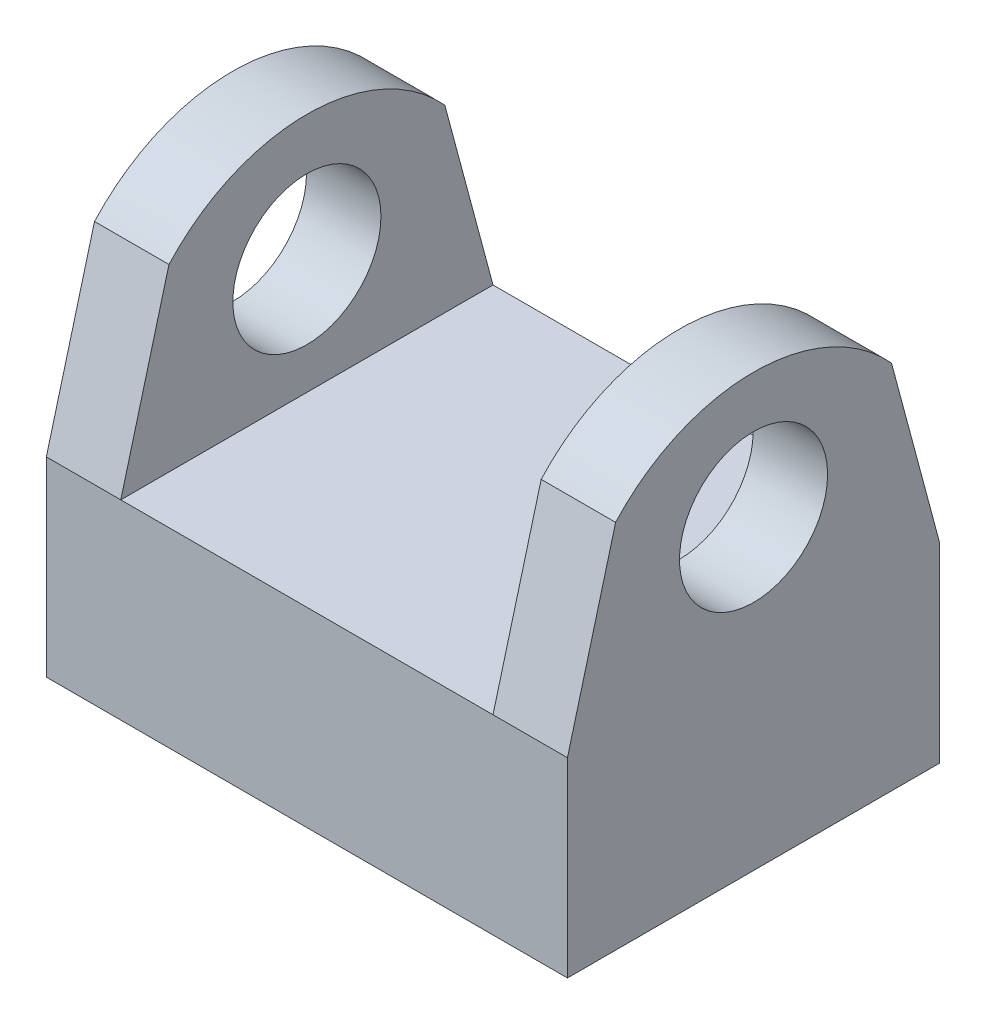
from build123d import *

# Parameters (mm, degrees)
SKETCH1_W           = 35.56
SKETCH1_H           = 25.4
BOSS_EXTRUDE1_DEPTH = 13.0175
BOSS_EXTRUDE2_DEPTH = 5.08
SKETCH3_R           = 5.053169443
CUT_EXTRUDE1_DEPTH  = 36.56


with BuildPart() as part:
    # Sketch1 → Boss-Extrude1 (new body)
    with BuildSketch(Plane(origin=(0, 0, 0), x_dir=(1, 0, 0), z_dir=(0, 1, 0))):
        Rectangle(SKETCH1_W, SKETCH1_H)
    extrude(amount=BOSS_EXTRUDE1_DEPTH)

    # Sketch2 → Boss-Extrude2 (add)
    with BuildSketch(Plane(origin=(17.78, 0, 0), x_dir=(0, 0, -1), z_dir=(1, 0, 0))):
        with BuildLine():
            Line((-12.7, 13.0175), (-9.412998127, 25.284757994))
            ThreePointArc((-9.412998127, 25.284757994), (0, 29.45408338), (9.412998127, 25.284757994))
            Line((9.412998127, 25.284757994), (12.7, 13.0175))
            Line((12.7, 13.0175), (-12.7, 13.0175))
        make_face()
    boss_extrude2 = extrude(amount=-BOSS_EXTRUDE2_DEPTH)

    # Mirror1: Boss-Extrude2 across plane
    add(boss_extrude2.mirror(Plane(origin=(0, 0, 0), x_dir=(0, 0, 1), z_dir=(1, 0, 0))))

    # Sketch3 → Cut-Extrude1 (cut, through all)
    with BuildSketch(Plane(origin=(17.78, 0, 0), x_dir=(0, 0, -1), z_dir=(1, 0, 0))):
        with Locations((0, 20.8915)):
            Circle(SKETCH3_R)
    extrude(amount=-CUT_EXTRUDE1_DEPTH, mode=Mode.SUBTRACT)


solid = part.part
